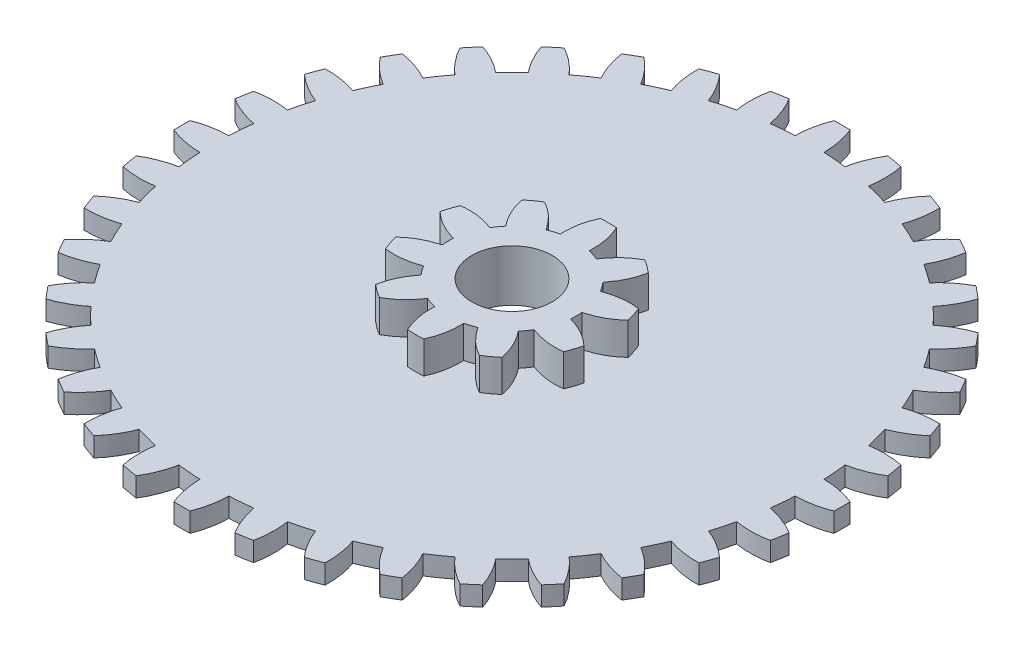
from build123d import *

# Parameters (mm, degrees)
SKETCH1_R           = 3.7
BOSS_EXTRUDE1_DEPTH = 0.24
BOSS_EXTRUDE2_DEPTH = 0.24
CIRPATTERN1_COUNT   = 36
SKETCH4_R           = 0.8
BOSS_EXTRUDE3_DEPTH = 0.4
BOSS_EXTRUDE4_DEPTH = 0.4
CIRPATTERN2_COUNT   = 10
SKETCH6_R           = 0.5
CUT_EXTRUDE1_DEPTH  = 1.6400001


with BuildPart() as part:
    # Sketch1 → Boss-Extrude1 (new body)
    with BuildSketch(Plane(origin=(0, 0, 0), x_dir=(1, 0, 0), z_dir=(0, 1, 0))):
        Circle(SKETCH1_R)
    extrude(amount=BOSS_EXTRUDE1_DEPTH)

    # Sketch3 → Boss-Extrude2 (add)
    with BuildSketch(Plane(origin=(0, 0, 0), x_dir=(1, 0, 0), z_dir=(0, 1, 0))):
        with BuildLine():
            ThreePointArc((-0.18, -3.695619028), (0, -3.7), (0.18, -3.695619028))
            add(Edge.make_bspline(
                [(0.1, -4.098780306), (0.143332763, -3.995796374), (0.179733851, -3.839207533), (0.18, -3.695619028)],
                knots=[0, 0, 0, 0, 1, 1, 1, 1], degree=3))
            ThreePointArc((0.1, -4.098780306), (0, -4.1), (-0.1, -4.098780306))
            add(Edge.make_bspline(
                [(-0.1, -4.098780306), (-0.143332763, -3.995796374), (-0.179733851, -3.839207533), (-0.18, -3.695619028)],
                knots=[0, 0, 0, 0, 1, 1, 1, 1], degree=3))
        make_face()
    boss_extrude2 = extrude(amount=BOSS_EXTRUDE2_DEPTH)

    # CirPattern1: Boss-Extrude2 ×36 about axis
    cirpattern1_axis = Axis((0, 0.24, 0), (0, -1, 0))
    for i in range(1, CIRPATTERN1_COUNT):
        add(boss_extrude2.rotate(cirpattern1_axis, i * 360 / CIRPATTERN1_COUNT))

    # Sketch4 → Boss-Extrude3 (add)
    with BuildSketch(Plane(origin=(0, 0.24, 0), x_dir=(1, 0, 0), z_dir=(0, 1, 0))):
        Circle(SKETCH4_R)
    extrude(amount=BOSS_EXTRUDE3_DEPTH)

    # Sketch5 → Boss-Extrude4 (add)
    with BuildSketch(Plane(origin=(0, 0.24, 0), x_dir=(1, 0, 0), z_dir=(0, 1, 0))):
        with BuildLine():
            ThreePointArc((-0.1, -1.195826074), (0, -1.2), (0.1, -1.195826074))
            add(Edge.make_bspline(
                [(0.18, -0.779487011), (0.186314143, -0.971701339), (0.150244567, -1.08552875), (0.1, -1.195826074)],
                knots=[0, 0, 0, 0, 1, 1, 1, 1], degree=3))
            ThreePointArc((0.18, -0.779487011), (0, -0.8), (-0.18, -0.779487011))
            add(Edge.make_bspline(
                [(-0.18, -0.779487011), (-0.186314143, -0.971701339), (-0.150244567, -1.08552875), (-0.1, -1.195826074)],
                knots=[0, 0, 0, 0, 1, 1, 1, 1], degree=3))
        make_face()
    boss_extrude4 = extrude(amount=BOSS_EXTRUDE4_DEPTH)

    # CirPattern2: Boss-Extrude4 ×10 about axis
    cirpattern2_axis = Axis((0, 0.64, 0), (0, -1, 0))
    for i in range(1, CIRPATTERN2_COUNT):
        add(boss_extrude4.rotate(cirpattern2_axis, i * 360 / CIRPATTERN2_COUNT))

    # Sketch6 → Cut-Extrude1 (cut, through all)
    with BuildSketch(Plane(origin=(0, 0.64, 0), x_dir=(1, 0, 0), z_dir=(0, 1, 0))):
        Circle(SKETCH6_R)
    extrude(amount=-CUT_EXTRUDE1_DEPTH, mode=Mode.SUBTRACT)


solid = part.part
